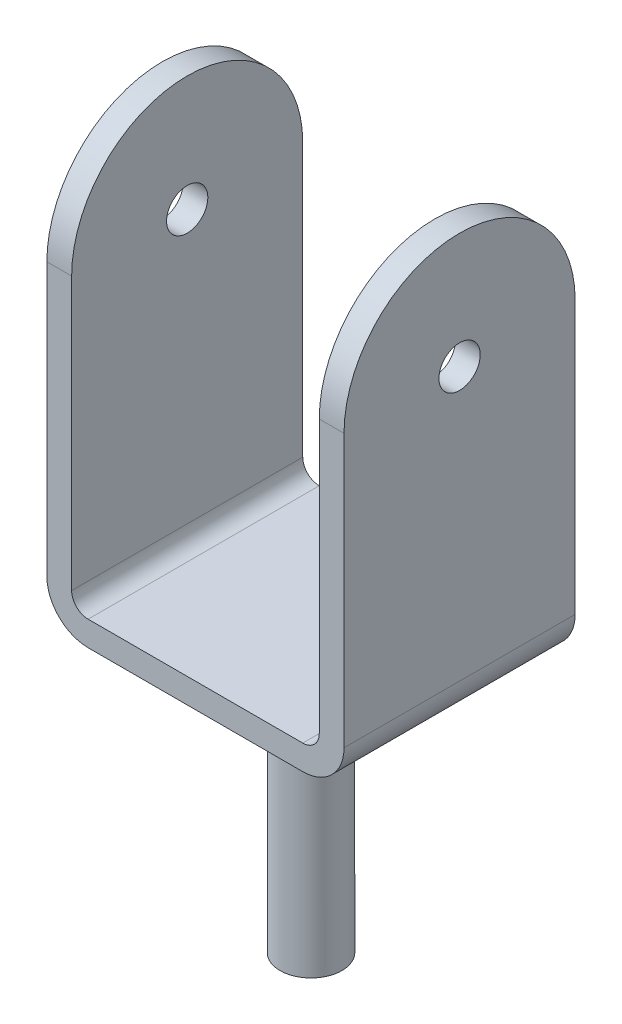
from build123d import *

# Parameters (mm, degrees)
BOSS_EXTRUDE2_DEPTH     = 280
BOSS_EXTRUDE3_START     = 150
SKETCH5_R               = 140
BOSS_EXTRUDE3_DEPTH     = 30
BOSS_EXTRUDE4_START     = -150
SKETCH5_2_R             = 140
BOSS_EXTRUDE4_DEPTH     = 30
SKETCH6_R               = 25
CUT_EXTRUDE1_DEPTH      = 181
CUT_EXTRUDE1_DEPTH_BACK = 181
SKETCH7_R               = 37.5
BOSS_EXTRUDE5_DEPTH     = 325


with BuildPart() as part:
    # Sketch4 → Boss-Extrude2 (new body)
    with BuildSketch(Plane.XY):
        with BuildLine():
            Line((-130, 0), (130, 0))
            ThreePointArc((130, 0), (165.355339059, 14.644660941), (180, 50))
            Line((180, 50), (180, 380))
            Line((180, 380), (150, 380))
            Line((150, 380), (150, 50))
            ThreePointArc((150, 50), (144.142135624, 35.857864376), (130, 30))
            Line((130, 30), (-130, 30))
            ThreePointArc((-130, 30), (-144.142135624, 35.857864376), (-150, 50))
            Line((-150, 50), (-150, 380))
            Line((-150, 380), (-180, 380))
            Line((-180, 380), (-180, 50))
            ThreePointArc((-180, 50), (-165.355339059, 14.644660941), (-130, 0))
        make_face()
    extrude(amount=-BOSS_EXTRUDE2_DEPTH)

    # Sketch5 → Boss-Extrude3 (add)
    with BuildSketch(Plane(origin=(0, 0, 0), x_dir=(0, 0, -1), z_dir=(1, 0, 0)).offset(BOSS_EXTRUDE3_START)):
        with Locations((140, 380)):
            Circle(SKETCH5_R)
    extrude(amount=BOSS_EXTRUDE3_DEPTH)

    # Sketch5_2 → Boss-Extrude4 (add)
    with BuildSketch(Plane(origin=(0, 0, 0), x_dir=(0, 0, -1), z_dir=(1, 0, 0)).offset(BOSS_EXTRUDE4_START)):
        with Locations((140, 380)):
            Circle(SKETCH5_2_R)
    extrude(amount=-BOSS_EXTRUDE4_DEPTH)

    # Sketch6 → Cut-Extrude1 (cut, two sides)
    with BuildSketch(Plane(origin=(0, 0, 0), x_dir=(0, 0, -1), z_dir=(1, 0, 0))) as cut_extrude1_sk:
        with Locations((140, 380)):
            Circle(SKETCH6_R)
    extrude(amount=CUT_EXTRUDE1_DEPTH, mode=Mode.SUBTRACT)
    extrude(cut_extrude1_sk.sketch, amount=-CUT_EXTRUDE1_DEPTH_BACK, mode=Mode.SUBTRACT)

    # Sketch7 → Boss-Extrude5 (add)
    with BuildSketch(Plane(origin=(0, 0, 0), x_dir=(1, 0, 0), z_dir=(0, 1, 0))):
        with Locations((0, 140)):
            Circle(SKETCH7_R)
    extrude(amount=-BOSS_EXTRUDE5_DEPTH)


solid = part.part
